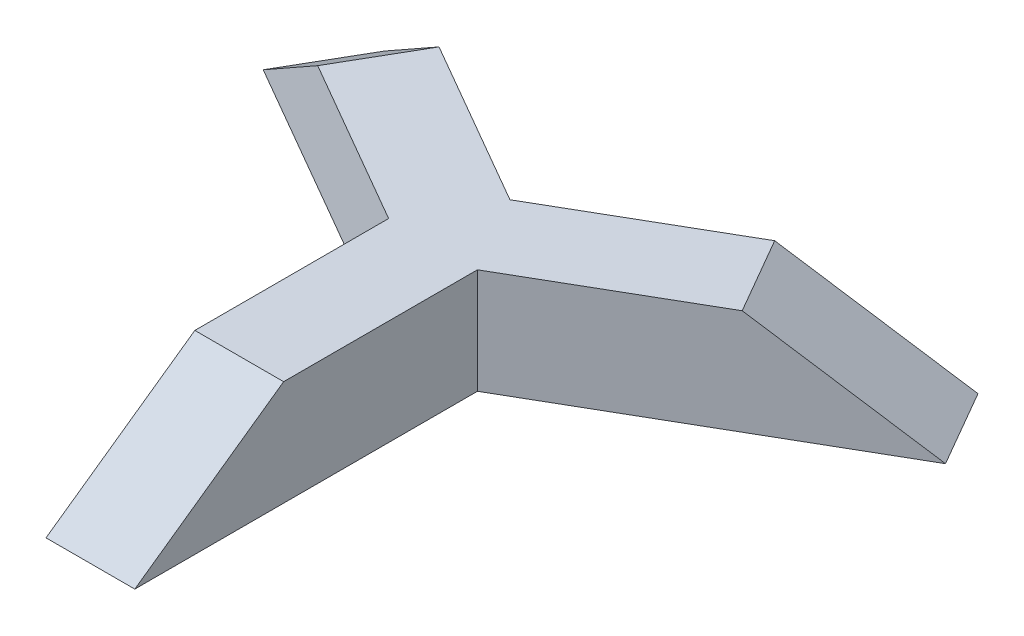
from build123d import *

# Parameters (mm, degrees)
BOSS_EXTRUDE2_DEPTH = 50
CUT_EXTRUDE1_DEPTH  = 42.2
CIRPATTERN1_COUNT   = 3


with BuildPart() as part:
    # Sketch3 → Boss-Extrude2 (new body)
    with BuildSketch(Plane(origin=(0, 0, 0), x_dir=(1, 0, 0), z_dir=(0, 1, 0))):
        Polygon((-21.1, -12.18209068), (-21.1, -175), (21.1, -175), (21.1, -12.18209068), (0, 0), align=None)
    boss_extrude2 = extrude(amount=BOSS_EXTRUDE2_DEPTH)

    # Sketch4 → Cut-Extrude1 (cut)
    with BuildSketch(Plane.ZY.offset(21.1)):
        Polygon((175, 0), (104.277828473, 50), (175, 50), align=None)
    cut_extrude1 = extrude(amount=-CUT_EXTRUDE1_DEPTH, mode=Mode.SUBTRACT)

    # CirPattern1: Boss-Extrude2, Cut-Extrude1 ×3 about axis
    cirpattern1_axis = Axis((0, 0, 0), (0, 1, 0))
    for i in range(1, CIRPATTERN1_COUNT):
        add(boss_extrude2.rotate(cirpattern1_axis, i * 360 / CIRPATTERN1_COUNT))
        add(cut_extrude1.rotate(cirpattern1_axis, i * 360 / CIRPATTERN1_COUNT), mode=Mode.SUBTRACT)


solid = part.part
